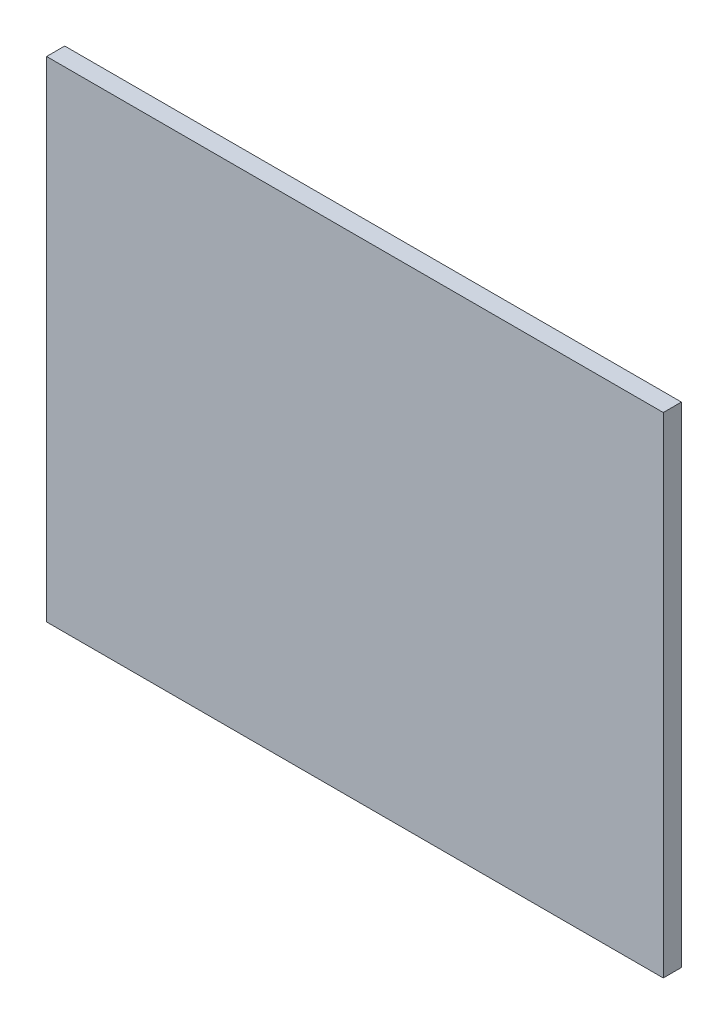
from build123d import *

# Parameters (mm, degrees)
SKETCH1_W           = 340
SKETCH1_H           = 270
BOSS_EXTRUDE1_DEPTH = 10


with BuildPart() as part:
    # Sketch1 → Boss-Extrude1 (new body)
    with BuildSketch(Plane.XY):
        with Locations((170, 135)):
            Rectangle(SKETCH1_W, SKETCH1_H)
    extrude(amount=BOSS_EXTRUDE1_DEPTH)


solid = part.part
